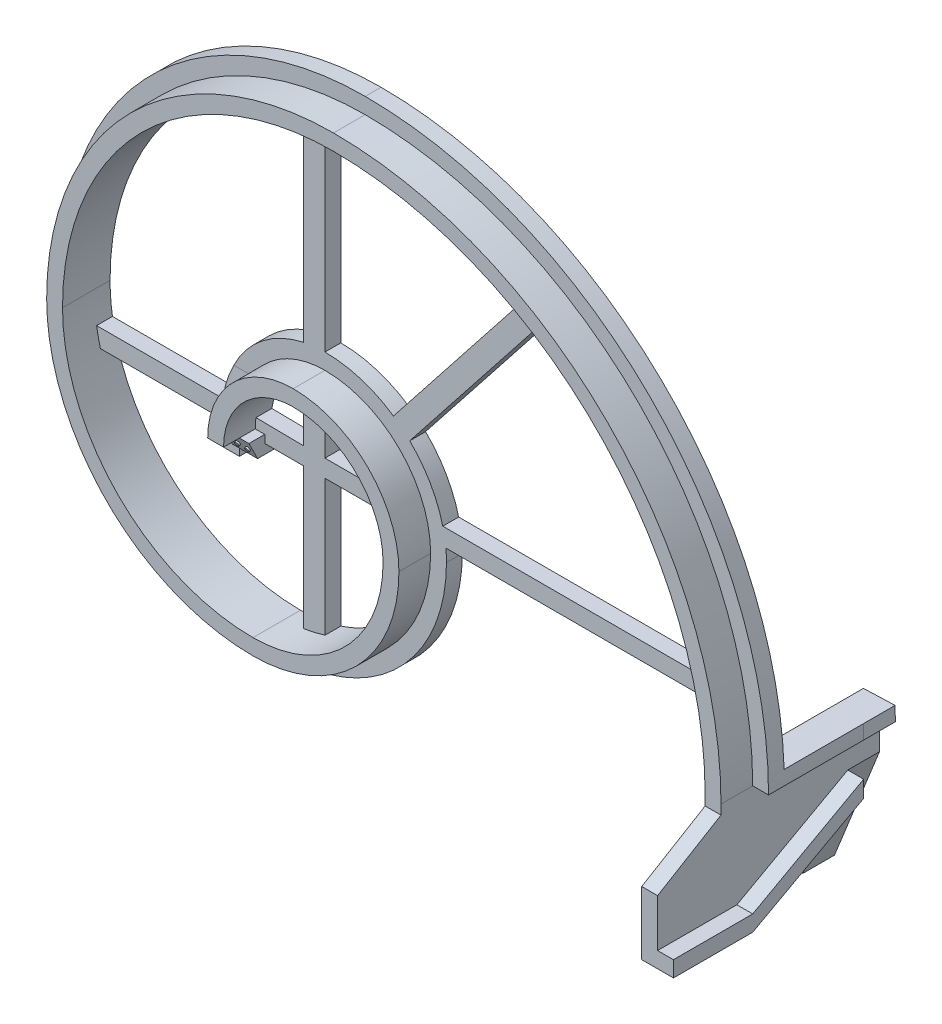
from build123d import *

# Parameters (mm, degrees)
EXTRUDE2_DEPTH      = 10
EXTRUDE3_DEPTH      = 5
CUT_EXTRUDE1_DEPTH  = 5
EXTRUDE4_DEPTH      = 3
CUT_EXTRUDE2_DEPTH  = 8
EXTRUDE5_DEPTH      = 5
EXTRUDE5_DEPTH_BACK = 5
CUT_EXTRUDE3_DEPTH  = 5
SKETCH9_W           = 5
SKETCH9_H           = 15
EXTRUDE6_DEPTH      = 35
SKETCH11_W          = 5
SKETCH11_H          = 35
EXTRUDE8_DEPTH      = 25
EXTRUDE9_DEPTH      = 25
EXTRUDE12_DEPTH     = 20
EXTRUDE13_DEPTH     = 5
CUT_EXTRUDE5_DEPTH  = 5
EXTRUDE14_DEPTH     = 10
EXTRUDE19_DEPTH     = 5
SKETCH21_R          = 0.7
EXTRUDE20_DEPTH     = 0.5


with BuildPart() as part:
    # Sketch2 → Extrude2 (new body)
    with BuildSketch(Plane.XY):
        with BuildLine():
            Line((-26.9875, 0), (-26.9875, -10))
            Line((-26.9875, -10), (-21.9875, -10))
            Line((-21.9875, -10), (-21.9875, 0))
            ThreePointArc((-21.9875, 0), (-15.547510351, 15.547510351), (0, 21.9875))
            ThreePointArc((0, 21.9875), (20.037638412, 13.687638412), (28.3375, -6.35))
            ThreePointArc((28.3375, -6.35), (16.317894533, -35.367894533), (-12.7, -47.3875))
            ThreePointArc((-12.7, -47.3875), (-55.188278715, -29.788278715), (-72.7875, 12.7))
            ThreePointArc((-72.7875, 12.7), (-47.748790957, 73.148790957), (12.7, 98.1875))
            ThreePointArc((12.7, 98.1875), (95.599431259, 63.849431259), (129.9375, -19.05))
            Line((129.9375, -19.05), (134.9375, -19.05))
            ThreePointArc((134.9375, -19.05), (99.134965165, 67.384965165), (12.7, 103.1875))
            ThreePointArc((12.7, 103.1875), (-51.284324863, 76.684324863), (-77.7875, 12.7))
            ThreePointArc((-77.7875, 12.7), (-58.72381262, -33.32381262), (-12.7, -52.3875))
            ThreePointArc((-12.7, -52.3875), (19.853428439, -38.903428439), (33.3375, -6.35))
            ThreePointArc((33.3375, -6.35), (23.573172318, 17.223172318), (0, 26.9875))
            ThreePointArc((0, 26.9875), (-19.083044257, 19.083044257), (-26.9875, 0))
        make_face()
    extrude(amount=EXTRUDE2_DEPTH)

    # Sketch3 → Extrude3 (add)
    with BuildSketch(Plane.XY):
        with BuildLine():
            Line((-21.9875, 0), (-21.9875, -10))
            Line((-21.9875, -10), (-31.9875, -10))
            Line((-31.9875, -10), (-31.9875, 0))
            ThreePointArc((-31.9875, 0), (-22.618578163, 22.618578163), (0, 31.9875))
            ThreePointArc((0, 31.9875), (27.108706224, 20.758706224), (38.3375, -6.35))
            ThreePointArc((38.3375, -6.35), (23.388962345, -42.438962345), (-12.7, -57.3875))
            ThreePointArc((-12.7, -57.3875), (-62.259346526, -36.859346526), (-82.7875, 12.7))
            ThreePointArc((-82.7875, 12.7), (-54.819858769, 80.219858769), (12.7, 108.1875))
            ThreePointArc((12.7, 108.1875), (102.670499071, 70.920499071), (139.9375, -19.05))
            Line((139.9375, -19.05), (129.9375, -19.05))
            ThreePointArc((129.9375, -19.05), (95.599431259, 63.849431259), (12.7, 98.1875))
            ThreePointArc((12.7, 98.1875), (-47.748790957, 73.148790957), (-72.7875, 12.7))
            ThreePointArc((-72.7875, 12.7), (-55.188278715, -29.788278715), (-12.7, -47.3875))
            ThreePointArc((-12.7, -47.3875), (16.317894533, -35.367894533), (28.3375, -6.35))
            ThreePointArc((28.3375, -6.35), (20.037638412, 13.687638412), (0, 21.9875))
            ThreePointArc((0, 21.9875), (-15.547510351, 15.547510351), (-21.9875, 0))
        make_face()
    extrude(amount=-EXTRUDE3_DEPTH)

    # Sketch4 → Cut-Extrude1 (cut)
    with BuildSketch(Plane.ZY.offset(26.9875)):
        Polygon((0, -10), (5, 0), (10, 0), (10, -10), align=None)
    extrude(amount=-CUT_EXTRUDE1_DEPTH, mode=Mode.SUBTRACT)

    # Sketch5 → Extrude4 (add)
    with BuildSketch(Plane(origin=(-21.9875, 0, 0), x_dir=(0, 0, -1), z_dir=(1, 0, 0))):
        Polygon((0, -10), (-5, 0), (0, 0), (5, 0), (5, -10), align=None)
    extrude(amount=EXTRUDE4_DEPTH)

    # Sketch6 → Cut-Extrude2 (cut)
    with BuildSketch(Plane(origin=(-18.9875, 0, 0), x_dir=(0, 0, -1), z_dir=(1, 0, 0))):
        Polygon((5, -5.5), (-2.25, -5.5), (0, -10), (5, -10), align=None)
    extrude(amount=-CUT_EXTRUDE2_DEPTH, mode=Mode.SUBTRACT)

    # Sketch7 → Extrude5 (add, two sides)
    with BuildSketch(Plane.ZY.offset(26.9875)) as extrude5_sk:
        Polygon((0, -5.5), (0.798113635, -5.5), (0, 14), align=None)
    extrude(amount=EXTRUDE5_DEPTH)
    extrude(extrude5_sk.sketch, amount=-EXTRUDE5_DEPTH_BACK)

    # Sketch8 → Cut-Extrude3 (cut)
    with BuildSketch(Plane.XY):
        with BuildLine():
            Line((-28.761087536, 14), (-31.9875, 14))
            Line((-31.9875, 14), (-31.9875, 0))
            ThreePointArc((-31.9875, 0), (-31.170462331, 7.183483441), (-28.761087536, 14))
        make_face()
    extrude(amount=CUT_EXTRUDE3_DEPTH, mode=Mode.SUBTRACT)

    # Sketch9 → Extrude6 (add)
    with BuildSketch(Plane.XZ.offset(19.05)):
        with Locations((132.4375, 2.5)):
            Rectangle(SKETCH9_W, SKETCH9_H)
    extrude(amount=EXTRUDE6_DEPTH)

    # Sketch11 → Extrude8 (add)
    with BuildSketch(Plane(origin=(0, 0, -5), x_dir=(-1, 0, 0), z_dir=(0, 0, -1))):
        with Locations((-132.4375, -36.55)):
            Rectangle(SKETCH11_W, SKETCH11_H)
    extrude(amount=EXTRUDE8_DEPTH)

    # Sketch12 → Extrude9 (add)
    with BuildSketch(Plane(origin=(0, 0, -5), x_dir=(-1, 0, 0), z_dir=(0, 0, -1))):
        with BuildLine():
            Line((-129.9375, -19.05), (-139.9375, -19.05))
            ThreePointArc((-139.9375, -19.05), (-139.918121112, -16.829399436), (-139.859990353, -14.609475288))
            Line((-139.859990353, -14.609475288), (-129.866082083, -14.958470255))
            ThreePointArc((-129.866082083, -14.958470255), (-129.919644161, -17.0039235), (-129.9375, -19.05))
        make_face()
    extrude(amount=EXTRUDE9_DEPTH)

    # Sketch16 → Extrude12 (add)
    with BuildSketch(Plane.XY.offset(10)):
        Polygon((129.9375, -19.05), (129.9375, -54.05), (139.9375, -54.05), (139.9375, -49.05), (134.9375, -49.05), (134.9375, -19.05), align=None)
    extrude(amount=EXTRUDE12_DEPTH)

    # Sketch17 → Extrude13 (add)
    with BuildSketch(Plane(origin=(134.9375, 0, 0), x_dir=(0, 0, -1), z_dir=(1, 0, 0))):
        Polygon((-10, -54.05), (-10, -49.05), (-5, -49.05), (30, -29.72873513), (30, -34.988734421), (-5, -54.05), align=None)
    extrude(amount=EXTRUDE13_DEPTH)

    # Sketch18 → Cut-Extrude5 (cut)
    with BuildSketch(Plane(origin=(134.9375, 0, 0), x_dir=(0, 0, -1), z_dir=(1, 0, 0))):
        Polygon((-5, -54.05), (30, -34.988734421), (30, -54.05), align=None)
        Polygon((-30, -19.05), (-30, -34.05), (-10, -22.05), (-10, -19.05), align=None)
    extrude(amount=-CUT_EXTRUDE5_DEPTH, mode=Mode.SUBTRACT)

    # Sketch19 → Extrude14 (add)
    with BuildSketch(Plane(origin=(0, 0, -30), x_dir=(-1, 0, 0), z_dir=(0, 0, -1))):
        Polygon((-134.9375, -19.05), (-134.9375, -29.72873513), (-120.74, -65.09), (-115.74, -65.09), (-129.9375, -29.72873513), (-129.866082083, -14.958470255), (-139.859990353, -14.609475288), (-139.9375, -19.05), align=None)
    extrude(amount=EXTRUDE14_DEPTH)

    # Sketch20 → Extrude19 (add)
    with BuildSketch(Plane.XY):
        with BuildLine():
            Line((128.760903372, -2.482015371), (38.141874641, -2.482015371))
            ThreePointArc((38.141874641, -2.482015371), (37.760120708, 0.278513435), (37.178841709, 3.004017073))
            Line((37.178841709, 3.004017073), (127.844482009, 3.004017073))
            ThreePointArc((127.844482009, 3.004017073), (128.335231203, 0.266436289), (128.760903372, -2.482015371))
        make_face()
        with BuildLine():
            Line((0, 31.9875), (0, 97.238882511))
            ThreePointArc((0, 97.238882511), (-3.385770157, 96.660470787), (-6.745571925, 95.946515776))
            Line((-6.745571925, 95.946515776), (-6.745571925, 31.268153378))
            ThreePointArc((-6.745571925, 31.268153378), (-3.391909497, 31.807154953), (0, 31.9875))
        make_face()
        with BuildLine():
            Line((-0.000749496, 21.987499987), (-0.000749496, 3.004017073))
            Line((-0.000749496, 3.004017073), (26.74913589, 3.004017073))
            ThreePointArc((26.74913589, 3.004017073), (27.547611511, 0.294020339), (28.072274599, -2.482015371))
            Line((28.072274599, -2.482015371), (0.080484541, -2.482015371))
            Line((0.080484541, -2.482015371), (0.080484541, -45.312306862))
            ThreePointArc((0.080484541, -45.312306862), (-3.298138872, -46.262230565), (-6.745571925, -46.919996909))
            Line((-6.745571925, -46.919996909), (-6.745571925, -2.482015371))
            Line((-6.745571925, -2.482015371), (-18.9875, -2.482015371))
            Line((-18.9875, -2.482015371), (-18.9875, 0))
            Line((-18.9875, 0), (-21.9875, 0))
            ThreePointArc((-21.9875, 0), (-21.928738235, 1.606423254), (-21.752767023, 3.20426015))
            Line((-21.752767023, 3.20426015), (-6.745571925, 3.004017073))
            Line((-6.745571925, 3.004017073), (-6.745571925, 20.92719321))
            ThreePointArc((-6.745571925, 20.92719321), (-3.414568171, 21.720747696), (-0.000749496, 21.987499987))
        make_face()
        with BuildLine():
            Line((-31.826606372, 3.20426015), (-50.922171332, 3.20426015))
            Line((-50.922171332, 3.20426015), (-72.032441219, 3.20426015))
            ThreePointArc((-72.032441219, 3.20426015), (-71.503716958, 0.345627166), (-70.83734731, -2.484087197))
            Line((-70.83734731, -2.484087197), (-50.922171332, -2.484087197))
            Line((-50.922171332, -2.484087197), (-31.9875, -2.484087197))
            Line((-31.9875, -2.484087197), (-31.9875, 0))
            ThreePointArc((-31.9875, 0), (-31.947251271, 1.604148518), (-31.826606372, 3.20426015))
        make_face()
        with BuildLine():
            Line((26.74913589, 21.11356924), (73.944333787, 80.918810062))
            ThreePointArc((73.944333787, 80.918810062), (71.049492521, 82.635633837), (68.106562726, 84.268653752))
            Line((68.106562726, 84.268653752), (21.610975976, 25.315906329))
            ThreePointArc((21.610975976, 25.315906329), (24.271176613, 23.326150223), (26.74913589, 21.11356924))
        make_face()
    extrude(amount=-EXTRUDE19_DEPTH)

    # Sketch21 → Extrude20 (add)
    with BuildSketch(Plane(origin=(0, -2, 4), x_dir=(1, 0, 0), z_dir=(0, -0.447213595, 0.894427191))):
        with Locations((-23.8075, -1)):
            Circle(SKETCH21_R)
        with Locations((-20.6275, -1)):
            Circle(SKETCH21_R)
    extrude(amount=EXTRUDE20_DEPTH)


solid = part.part
